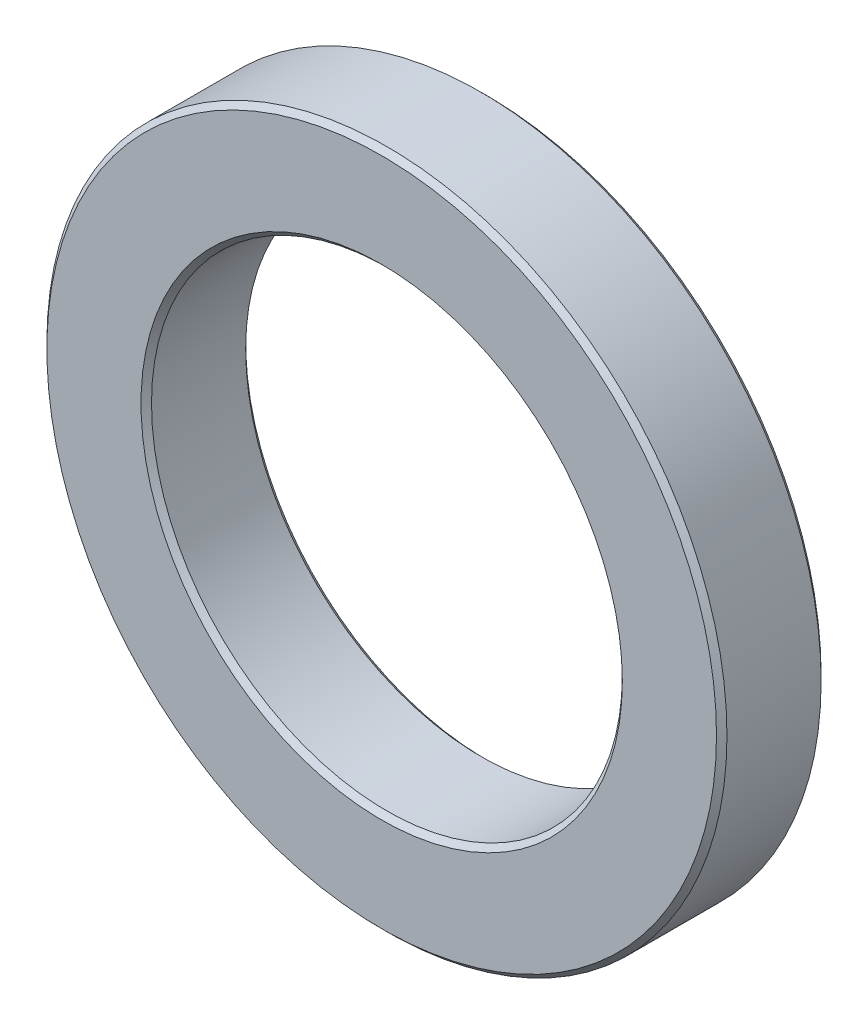
from build123d import *

# Parameters (mm, degrees)
SKETCH3_R           = 32.5
SKETCH3_R_2         = 22.5
BOSS_EXTRUDE1_DEPTH = 10
CHAMFER1_SIZE       = 0.5


with BuildPart() as part:
    # Sketch3 → Boss-Extrude1 (new body)
    with BuildSketch(Plane.XY):
        Circle(SKETCH3_R)
        Circle(SKETCH3_R_2, mode=Mode.SUBTRACT)
    extrude(amount=BOSS_EXTRUDE1_DEPTH)

    # Chamfer1
    chamfer1_edges = [part.edges().sort_by_distance(p)[0] for p in [
        (-32.5, 0, 0),
        (-32.5, 0, 10),
        (-22.5, 0, 0),
        (-22.5, 0, 10),
    ]]
    chamfer(chamfer1_edges, length=CHAMFER1_SIZE)


solid = part.part
